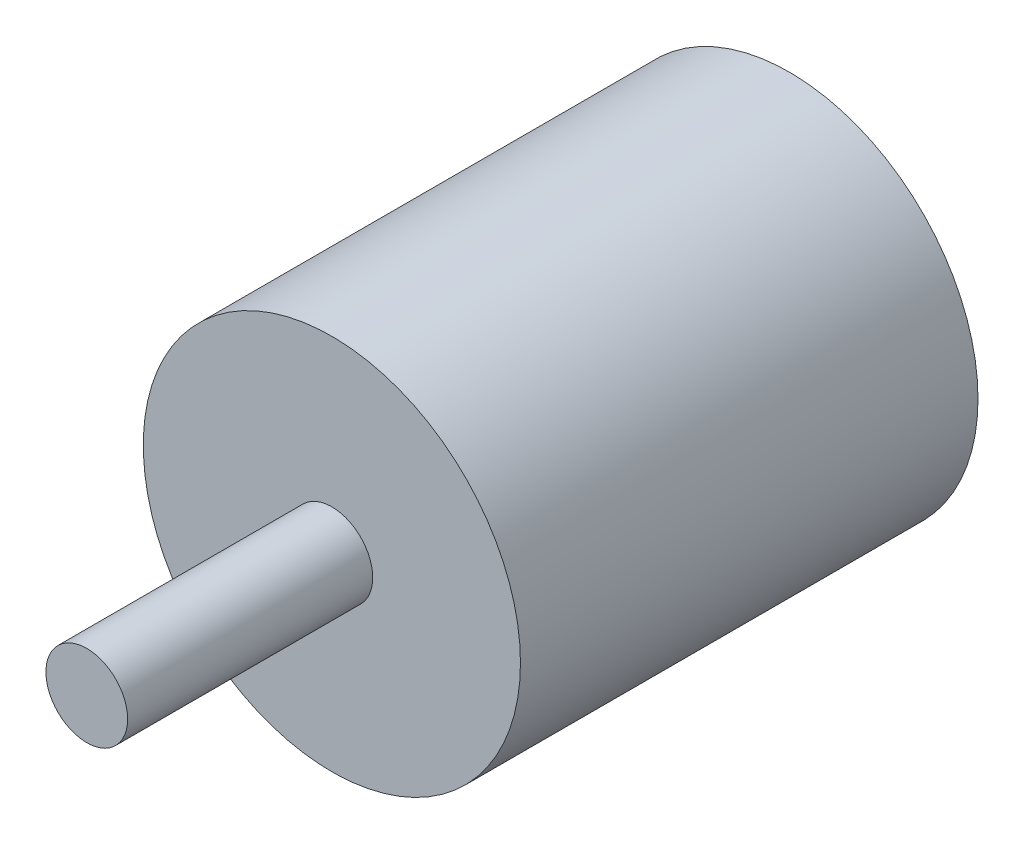
from build123d import *

# Parameters (mm, degrees)
SKETCH1_R           = 13.85
BOSS_EXTRUDE1_DEPTH = 33.6
SKETCH2_R           = 3
BOSS_EXTRUDE2_DEPTH = 18
SKETCH4_R           = 1.215
SKETCH4_R_2         = 1.526666667
CUT_EXTRUDE1_DEPTH  = 8


with BuildPart() as part:
    # Sketch1 → Boss-Extrude1 (new body)
    with BuildSketch(Plane.XY):
        Circle(SKETCH1_R)
    extrude(amount=BOSS_EXTRUDE1_DEPTH)

    # Sketch2 → Boss-Extrude2 (add)
    with BuildSketch(Plane.XY.offset(33.6)):
        Circle(SKETCH2_R)
    extrude(amount=BOSS_EXTRUDE2_DEPTH)

    # Sketch4 → Cut-Extrude1 (cut)
    with BuildSketch(Plane(origin=(0, 0, 0), x_dir=(-1, 0, 0), z_dir=(0, 0, -1))):
        with Locations((-9.515, 0)):
            Circle(SKETCH4_R)
        with Locations((9.515, 0)):
            Circle(SKETCH4_R)
        with Locations((0, 7.593333333)):
            Circle(SKETCH4_R_2)
        with Locations((0, -7.593333333)):
            Circle(SKETCH4_R_2)
    extrude(amount=-CUT_EXTRUDE1_DEPTH, mode=Mode.SUBTRACT)


solid = part.part
